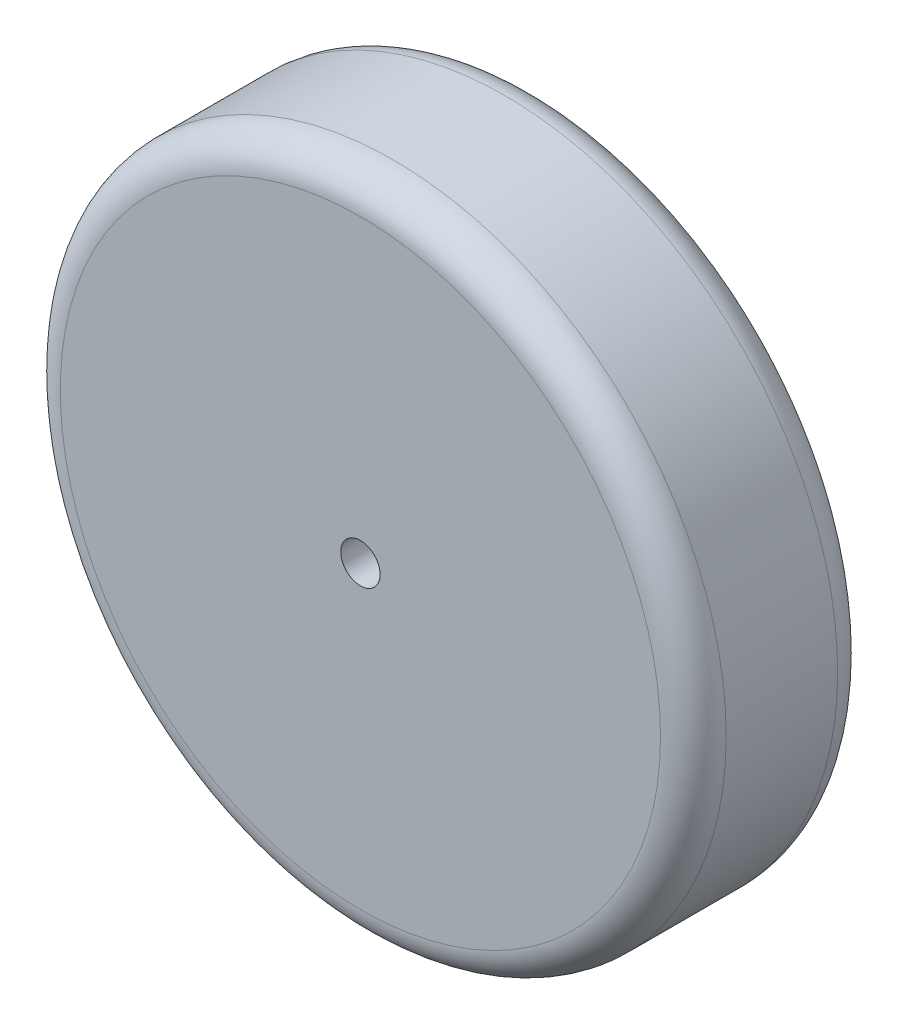
from build123d import *

# Parameters (mm, degrees)
SKETCH_1_R          = 101.5
EXTRUDE_1_DEPTH     = 54
FILLET_1_R          = 10
SKETCH_2_R          = 6
CUT_EXTRUDE_1_DEPTH = 54


with BuildPart() as part:
    # 草圖1 → 填料-伸長1 (new body)
    with BuildSketch(Plane.XY):
        Circle(SKETCH_1_R)
    extrude(amount=EXTRUDE_1_DEPTH)

    # 圓角1
    fillet_1_edges = [part.edges().sort_by_distance(p)[0] for p in [
        (-101.5, 0, 0),
        (-101.5, 0, 54),
    ]]
    fillet(fillet_1_edges, radius=FILLET_1_R)

    # 草圖2 → 除料-伸長1 (cut)
    with BuildSketch(Plane(origin=(0, 0, 0), x_dir=(-1, 0, 0), z_dir=(0, 0, -1))):
        Circle(SKETCH_2_R)
    extrude(amount=-CUT_EXTRUDE_1_DEPTH, mode=Mode.SUBTRACT)


solid = part.part
